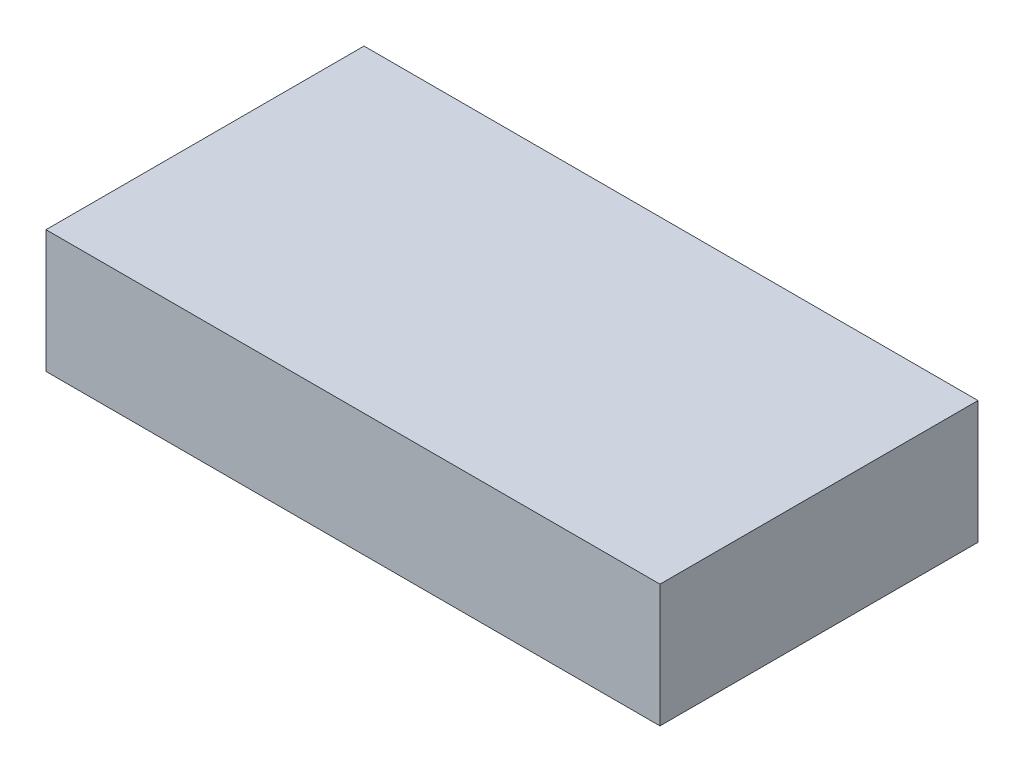
from build123d import *

# Parameters (mm, degrees)
SKETCH1_W           = 50
SKETCH1_H           = 25.9
BOSS_EXTRUDE1_DEPTH = 10


with BuildPart() as part:
    # Sketch1 → Boss-Extrude1 (new body)
    with BuildSketch(Plane(origin=(0, 0, 0), x_dir=(1, 0, 0), z_dir=(0, 1, 0))):
        with Locations((-49.740837232, -19.7426596)):
            Rectangle(SKETCH1_W, SKETCH1_H)
    extrude(amount=BOSS_EXTRUDE1_DEPTH)


solid = part.part
